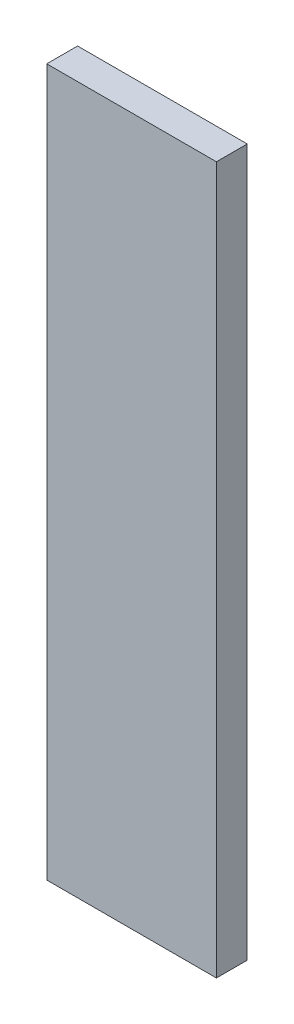
from build123d import *

# Parameters (mm, degrees)
BOSS_EXTRUDE1_DEPTH = 6
SKETCH2_W           = 66
SKETCH2_H           = 275
BOSS_EXTRUDE2_DEPTH = 6
SKETCH3_R           = 10
CUT_EXTRUDE1_DEPTH  = 6


with BuildPart() as part:
    # Sketch1 → Boss-Extrude1 (new body)
    with BuildSketch(Plane.XY):
        Polygon((23, 255), (23, 0), (43, 0), (43, 275), (-23, 275), (-23, 255), align=None)
    extrude(amount=-BOSS_EXTRUDE1_DEPTH)

    # Sketch2 → Boss-Extrude2 (add)
    with BuildSketch(Plane.XY):
        with Locations((10, 137.5)):
            Rectangle(SKETCH2_W, SKETCH2_H)
    extrude(amount=BOSS_EXTRUDE2_DEPTH)

    # Sketch3 → Cut-Extrude1 (cut)
    with BuildSketch(Plane(origin=(0, 0, -6), x_dir=(-1, 0, 0), z_dir=(0, 0, -1))):
        with Locations((-23, 255)):
            Circle(SKETCH3_R)
    extrude(amount=-CUT_EXTRUDE1_DEPTH, mode=Mode.SUBTRACT)


solid = part.part
